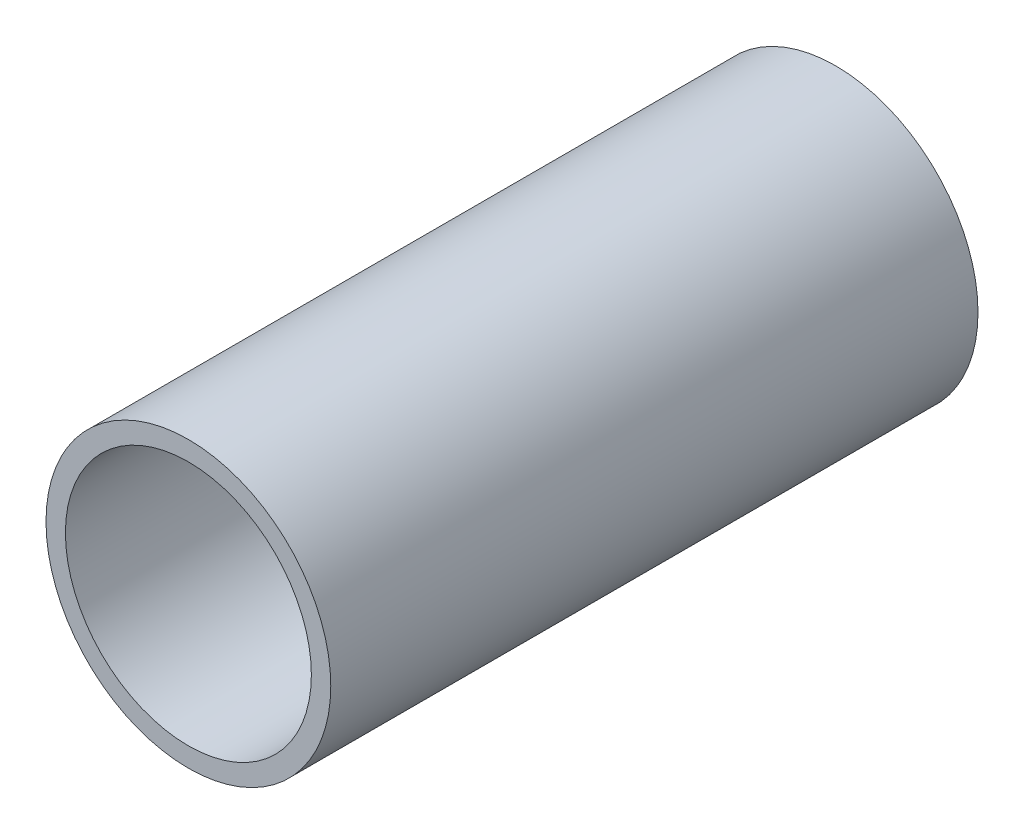
from build123d import *

# Parameters (mm, degrees)
SKETCH1_R           = 22
SKETCH1_R_2         = 19
BOSS_EXTRUDE1_DEPTH = 100


with BuildPart() as part:
    # Sketch1 → Boss-Extrude1 (new body)
    with BuildSketch(Plane.XY):
        Circle(SKETCH1_R)
        Circle(SKETCH1_R_2, mode=Mode.SUBTRACT)
    extrude(amount=BOSS_EXTRUDE1_DEPTH)


solid = part.part
